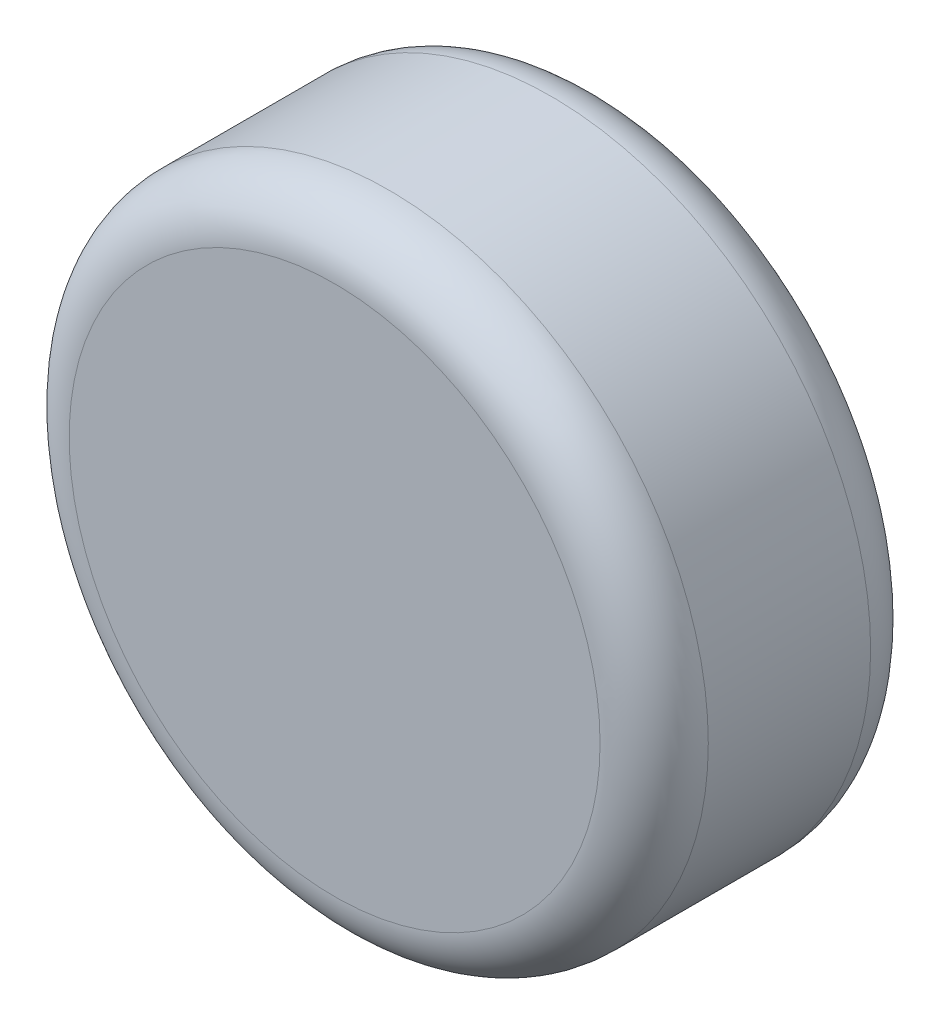
from build123d import *

# Parameters (mm, degrees)
SKETCH1_R           = 15
BOSS_EXTRUDE1_DEPTH = 12.7
FILLET1_R           = 2.54


with BuildPart() as part:
    # Sketch1 → Boss-Extrude1 (new body)
    with BuildSketch(Plane(origin=(39.613167077, -21.595737593, -219.505144919), x_dir=(1, 0, 0), z_dir=(0, 0, 1))):
        with Locations((23.631178541, 58.278681693)):
            Circle(SKETCH1_R)
    extrude(amount=BOSS_EXTRUDE1_DEPTH)

    # Fillet1
    fillet1_edges = [part.edges().sort_by_distance(p)[0] for p in [
        (48.244345617, 36.6829441, -219.505144919),
        (48.244345617, 36.6829441, -206.805144919),
    ]]
    fillet(fillet1_edges, radius=FILLET1_R)


solid = part.part
